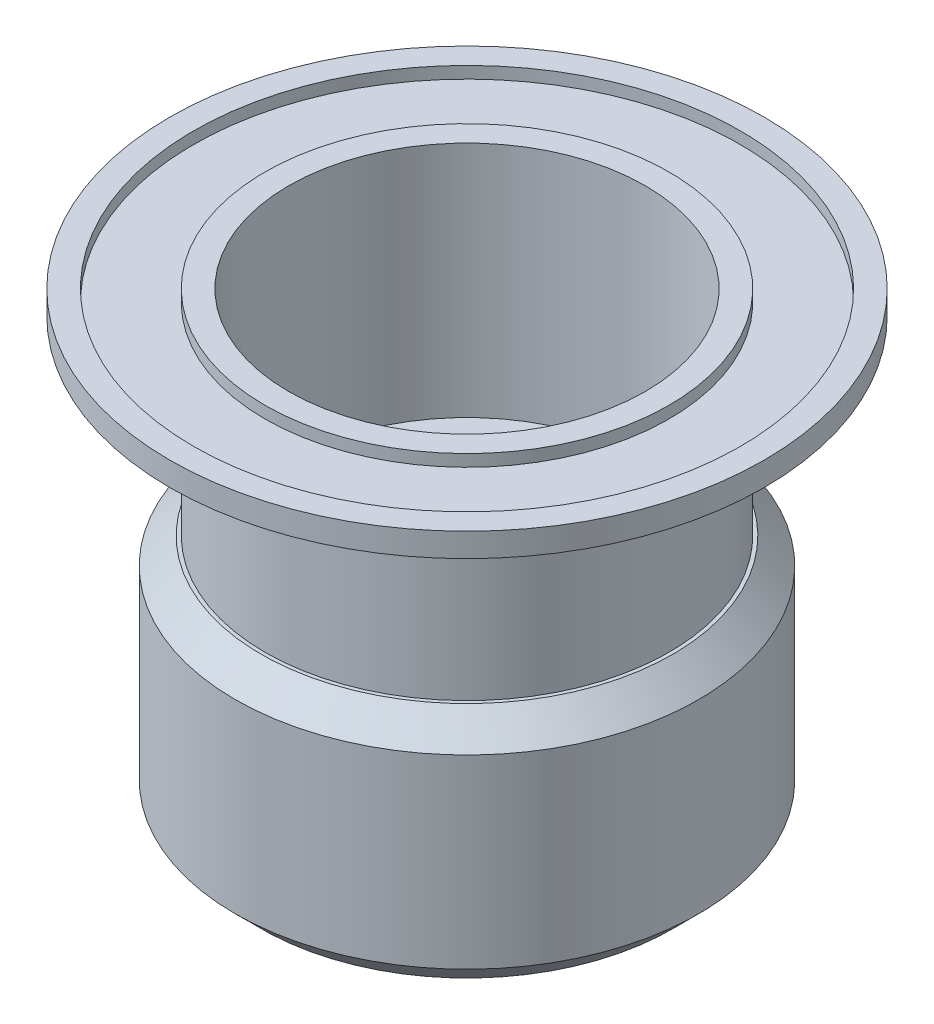
from build123d import *

# Parameters (mm, degrees)
SKETCH_3_R          = 23
SKETCH_3_R_2        = 17
CUT_EXTRUDE_1_DEPTH = 1
SKETCH_4_W          = 10
SKETCH_4_H          = 10
CUT_EXTRUDE_2_DEPTH = 1.5
SKETCH_5_R          = 4
CUT_EXTRUDE_3_DEPTH = 3
SKETCH_9_R          = 17
SKETCH_9_R_2        = 4
EXTRUDE_1_DEPTH     = 1
SKETCH_10_R         = 17
SKETCH_10_R_2       = 15
EXTRUDE_2_DEPTH     = 15
SKETCH_11_R         = 2.75
CUT_EXTRUDE_4_DEPTH = 17.5
SKETCH_12_R         = 19.5
SKETCH_12_R_2       = 17
EXTRUDE_3_DEPTH     = 20
CHAMFER_1_SIZE      = 2.195


with BuildPart() as part:
    # Эскиз2 → Повернуть1 (revolve)
    with BuildSketch(Plane.XY):
        Polygon((15, 0), (15, -20), (0, -20), (0, -22), (17, -22), (17, -2), (25, -2), (25, 0), align=None)
    revolve(axis=Axis((0, 0, 0), (0, -1, 0)))

    # Эскиз3 → Вырез-Вытянуть1 (cut)
    with BuildSketch(Plane(origin=(0, 0, 0), x_dir=(1, 0, 0), z_dir=(0, 1, 0))):
        Circle(SKETCH_3_R)
        Circle(SKETCH_3_R_2, mode=Mode.SUBTRACT)
    extrude(amount=-CUT_EXTRUDE_1_DEPTH, mode=Mode.SUBTRACT)

    # Эскиз4 → Вырез-Вытянуть2 (cut)
    with BuildSketch(Plane(origin=(0, -20, 0), x_dir=(1, 0, 0), z_dir=(0, 1, 0))):
        Rectangle(SKETCH_4_W, SKETCH_4_H)
    extrude(amount=-CUT_EXTRUDE_2_DEPTH, mode=Mode.SUBTRACT)

    # Эскиз5 → Вырез-Вытянуть3 (cut, through all)
    with BuildSketch(Plane(origin=(0, -20, 0), x_dir=(1, 0, 0), z_dir=(0, 1, 0))):
        with Locations((0, 10)):
            Circle(SKETCH_5_R)
        with Locations((10, 0)):
            Circle(SKETCH_5_R)
        with Locations((0, -10)):
            Circle(SKETCH_5_R)
        with Locations((-10, 0)):
            Circle(SKETCH_5_R)
    extrude(amount=-CUT_EXTRUDE_3_DEPTH, mode=Mode.SUBTRACT)

    # Эскиз9 → Бобышка-Вытянуть1 (add)
    with BuildSketch(Plane.XZ.offset(22)):
        Circle(SKETCH_9_R)
        with Locations((0, 10)):
            Circle(SKETCH_9_R_2, mode=Mode.SUBTRACT)
        with Locations((-10, 0)):
            Circle(SKETCH_9_R_2, mode=Mode.SUBTRACT)
        with Locations((0, -10)):
            Circle(SKETCH_9_R_2, mode=Mode.SUBTRACT)
        with Locations((10, 0)):
            Circle(SKETCH_9_R_2, mode=Mode.SUBTRACT)
    extrude(amount=EXTRUDE_1_DEPTH)

    # Эскиз10 → Бобышка-Вытянуть2 (add)
    with BuildSketch(Plane.XZ.offset(23)):
        Circle(SKETCH_10_R)
        Circle(SKETCH_10_R_2, mode=Mode.SUBTRACT)
    extrude(amount=EXTRUDE_2_DEPTH)

    # Эскиз11 → Вырез-Вытянуть4 (cut, through all)
    with BuildSketch(Plane(origin=(0, -21.5, 0), x_dir=(1, 0, 0), z_dir=(0, 1, 0))):
        Circle(SKETCH_11_R)
    extrude(amount=-CUT_EXTRUDE_4_DEPTH, mode=Mode.SUBTRACT)

    # Эскиз12 → Бобышка-Вытянуть3 (add)
    with BuildSketch(Plane.XZ.offset(38)):
        Circle(SKETCH_12_R)
        Circle(SKETCH_12_R_2, mode=Mode.SUBTRACT)
    extrude(amount=-EXTRUDE_3_DEPTH)

    # Фаска1
    chamfer_1_edges = [part.edges().sort_by_distance(p)[0] for p in [
        (-19.5, -18, 0),
        (-19.5, -38, 0),
    ]]
    chamfer(chamfer_1_edges, length=CHAMFER_1_SIZE)


solid = part.part
